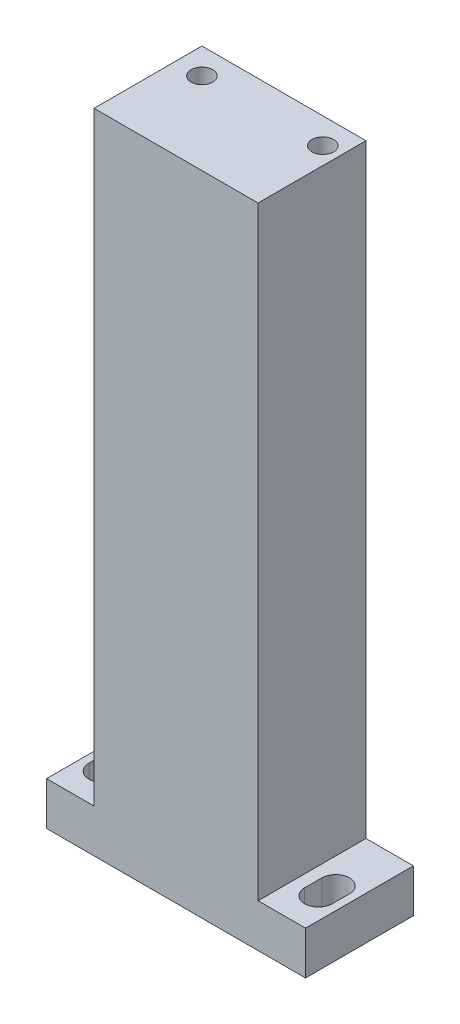
from build123d import *

# Parameters (mm, degrees)
ESBO_O1_W                = 60
ESBO_O1_H                = 25
RESSALTO_EXTRUS_O1_DEPTH = 10
ESBO_O7_W                = 38
ESBO_O7_H                = 25
RESSALTO_EXTRUS_O3_DEPTH = 140
ESBO_O8_R                = 2.5
CORTE_EXTRUS_O4_DEPTH    = 20
CORTE_EXTRUS_O5_DEPTH    = 20


with BuildPart() as part:
    # Esboço1 → Ressalto-extrusão1 (new body)
    with BuildSketch(Plane(origin=(0, 0, 0), x_dir=(1, 0, 0), z_dir=(0, 1, 0))):
        Rectangle(ESBO_O1_W, ESBO_O1_H)
    extrude(amount=RESSALTO_EXTRUS_O1_DEPTH)

    # Esboço7 → Ressalto-extrusão3 (add)
    with BuildSketch(Plane(origin=(0, 10, 0), x_dir=(1, 0, 0), z_dir=(0, 1, 0))):
        Rectangle(ESBO_O7_W, ESBO_O7_H)
    extrude(amount=RESSALTO_EXTRUS_O3_DEPTH)

    # Esboço8 → Corte-extrusão4 (cut)
    with BuildSketch(Plane(origin=(0, 150, 0), x_dir=(1, 0, 0), z_dir=(0, 1, 0))):
        with Locations((-13, 6.5)):
            Circle(ESBO_O8_R)
        with Locations((15, 6.5)):
            Circle(ESBO_O8_R)
    extrude(amount=-CORTE_EXTRUS_O4_DEPTH, mode=Mode.SUBTRACT)

    # Esboço9 → Corte-extrusão5 (cut)
    with BuildSketch(Plane(origin=(0, 10, 0), x_dir=(1, 0, 0), z_dir=(0, 1, 0))):
        with BuildLine():
            Line((-28.2, -4.5), (-28.2, -0.5))
            ThreePointArc((-28.2, -0.5), (-25, 2.7), (-21.8, -0.5))
            Line((-21.8, -0.5), (-21.8, -4.5))
            ThreePointArc((-21.8, -4.5), (-25, -7.7), (-28.2, -4.5))
        make_face()
        with BuildLine():
            Line((21.8, -4.5), (21.8, -0.5))
            ThreePointArc((21.8, -0.5), (25, 2.7), (28.2, -0.5))
            Line((28.2, -0.5), (28.2, -4.5))
            ThreePointArc((28.2, -4.5), (25, -7.7), (21.8, -4.5))
        make_face()
    extrude(amount=-CORTE_EXTRUS_O5_DEPTH, mode=Mode.SUBTRACT)


solid = part.part
